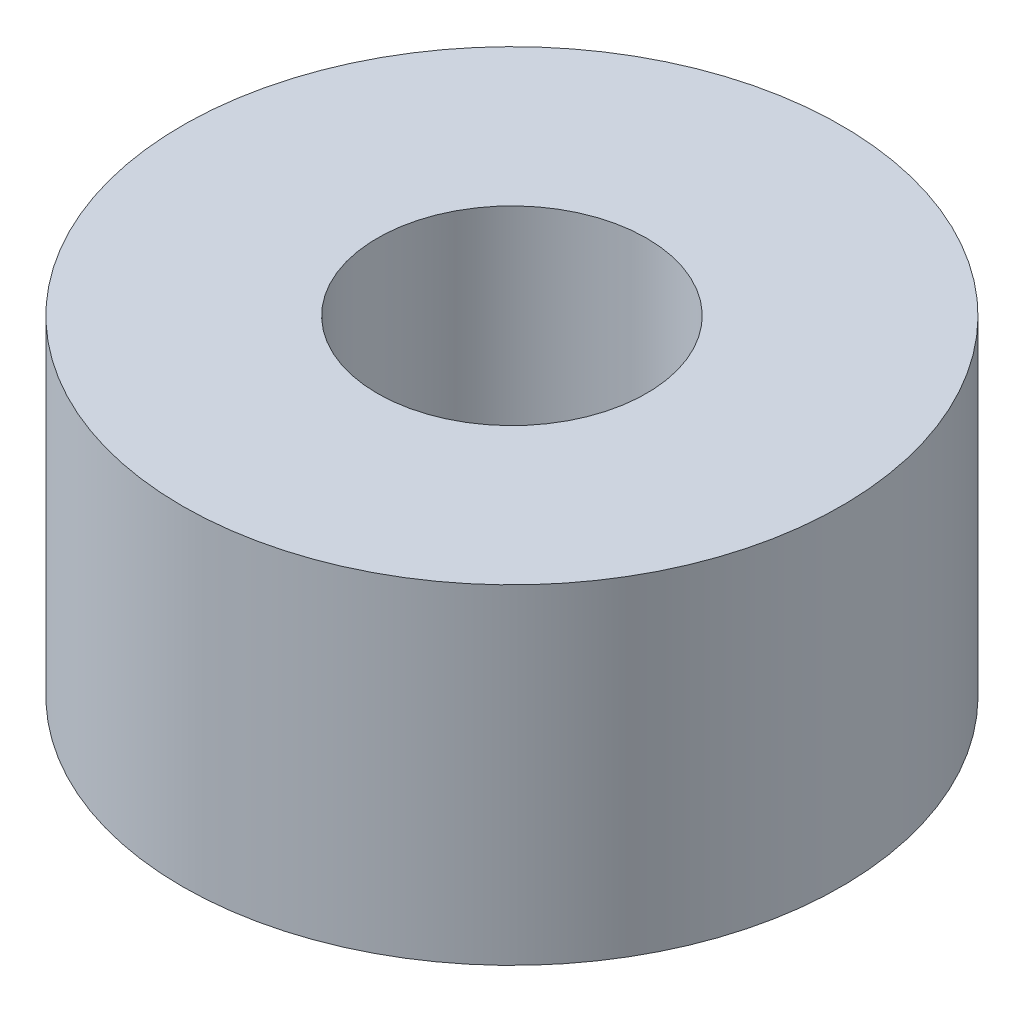
from build123d import *

# Parameters (mm, degrees)
SKETCH_1_R      = 3
SKETCH_1_R_2    = 1.225
EXTRUDE_1_DEPTH = 3


with BuildPart() as part:
    # 草图1 → 凸台-拉伸1 (new body)
    with BuildSketch(Plane(origin=(0, 0, 0), x_dir=(1, 0, 0), z_dir=(0, 1, 0))):
        with Locations((20, 4.950130432)):
            Circle(SKETCH_1_R)
        with Locations((20, 4.950130432)):
            Circle(SKETCH_1_R_2, mode=Mode.SUBTRACT)
    extrude(amount=EXTRUDE_1_DEPTH)


solid = part.part
